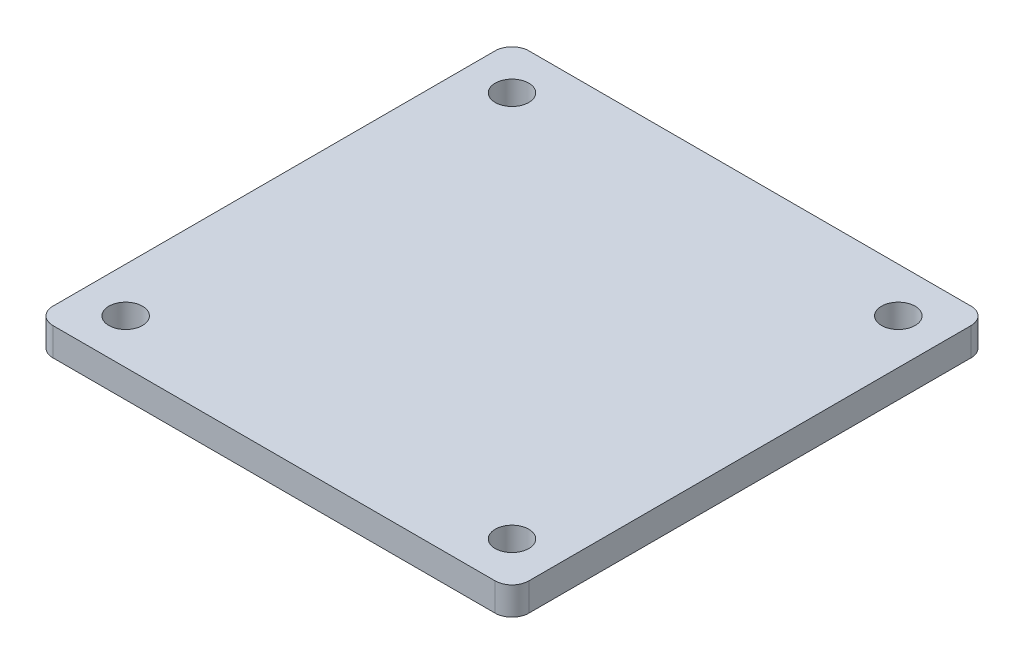
from build123d import *

# Parameters (mm, degrees)
SKETCH1_W           = 85
SKETCH1_H           = 85
BOSS_EXTRUDE1_DEPTH = 5
FILLET1_R           = 3
SKETCH2_R           = 3
CUT_EXTRUDE1_DEPTH  = 6


with BuildPart() as part:
    # Sketch1 → Boss-Extrude1 (new body)
    with BuildSketch(Plane(origin=(0, 0, 0), x_dir=(1, 0, 0), z_dir=(0, 1, 0))):
        Rectangle(SKETCH1_W, SKETCH1_H)
    extrude(amount=BOSS_EXTRUDE1_DEPTH)

    # Fillet1
    fillet1_edges = [part.edges().sort_by_distance(p)[0] for p in [
        (42.5, 2.5, 42.5),
        (-42.5, 2.5, 42.5),
        (-42.5, 2.5, -42.5),
        (42.5, 2.5, -42.5),
    ]]
    fillet(fillet1_edges, radius=FILLET1_R)

    # Sketch2 → Cut-Extrude1 (cut, through all)
    with BuildSketch(Plane(origin=(0, 5, 0), x_dir=(1, 0, 0), z_dir=(0, 1, 0))):
        with Locations((-34.5, 34.5)):
            Circle(SKETCH2_R)
        with Locations((-34.5, -34.5)):
            Circle(SKETCH2_R)
        with Locations((34.5, -34.5)):
            Circle(SKETCH2_R)
        with Locations((34.5, 34.5)):
            Circle(SKETCH2_R)
    extrude(amount=-CUT_EXTRUDE1_DEPTH, mode=Mode.SUBTRACT)


solid = part.part
